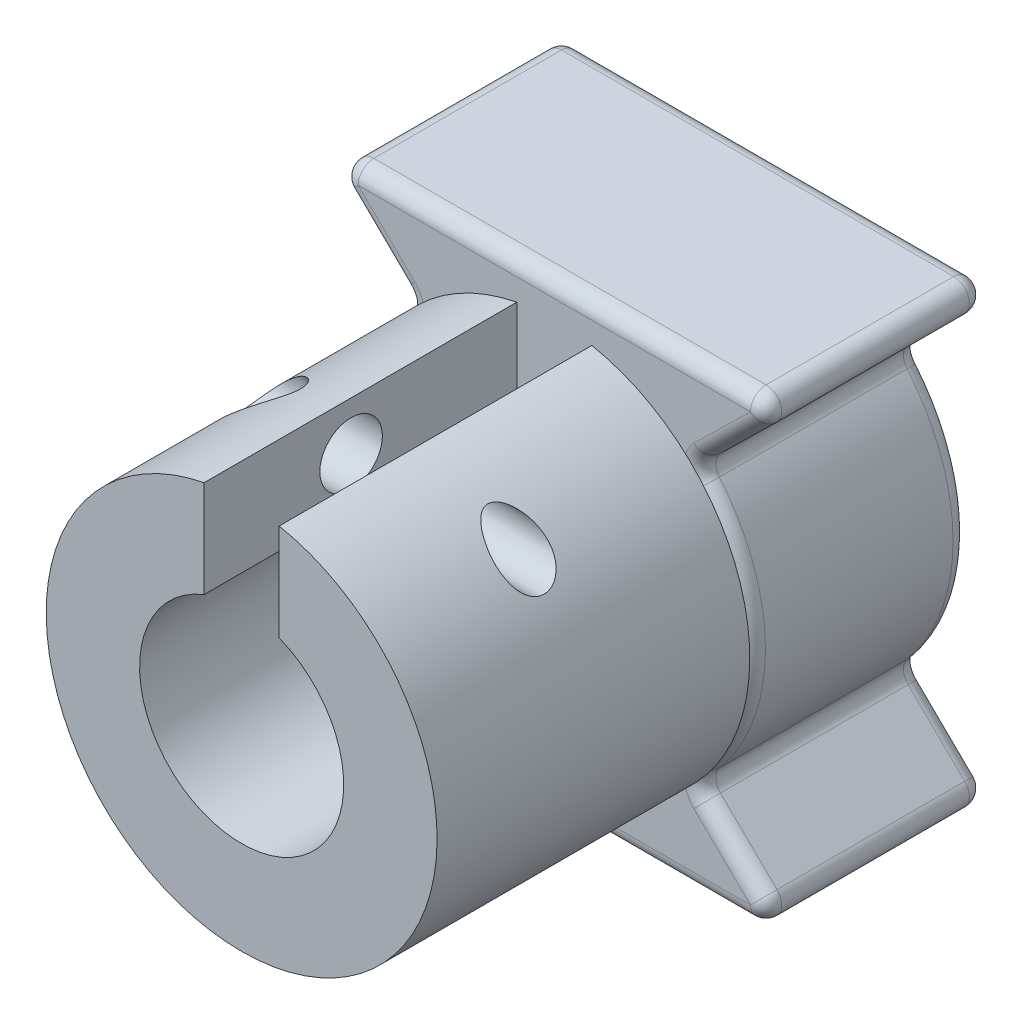
from build123d import *

# Parameters (mm, degrees)
SKETCH1_R           = 6.25
SKETCH1_R_2         = 3.2639
BOSS_EXTRUDE1_DEPTH = 10
SKETCH2_R           = 3.2639
BOSS_EXTRUDE2_DEPTH = 7
SKETCH3_W           = 2.4
SKETCH3_H           = 5.152631641
CUT_EXTRUDE1_DEPTH  = 10
SKETCH4_R           = 1
CUT_EXTRUDE2_DEPTH  = 8.5
SKETCH5_R           = 0.8
M2X_4_THREAD_DEPTH  = 9.5
FILLET2_R           = 0.5


with BuildPart() as part:
    # Sketch1 → Boss-Extrude1 (new body)
    with BuildSketch(Plane.XY):
        Circle(SKETCH1_R)
        Circle(SKETCH1_R_2, mode=Mode.SUBTRACT)
    extrude(amount=BOSS_EXTRUDE1_DEPTH)

    # Sketch3 → Cut-Extrude1 (cut)
    with BuildSketch(Plane.XY.offset(10)):
        with Locations((0, 4.528492236)):
            Rectangle(SKETCH3_W, SKETCH3_H)
    extrude(amount=-CUT_EXTRUDE1_DEPTH, mode=Mode.SUBTRACT)

    # Sketch4 → Cut-Extrude2 (cut, through all)
    with BuildSketch(Plane(origin=(0, 0, 0), x_dir=(0, 0, -1), z_dir=(1, 0, 0))):
        with Locations((-5.3, 4.584508905)):
            Circle(SKETCH4_R)
    extrude(amount=-CUT_EXTRUDE2_DEPTH, mode=Mode.SUBTRACT)

    # Sketch5 → m2x.4 thread (cut)
    with BuildSketch(Plane(origin=(0, 0, 0), x_dir=(0, 0, -1), z_dir=(1, 0, 0))):
        with Locations((-5.3, 4.584508905)):
            Circle(SKETCH5_R)
    extrude(amount=M2X_4_THREAD_DEPTH, mode=Mode.SUBTRACT)


with BuildPart() as body_2:
    # Sketch2 → Boss-Extrude2 (new body)
    with BuildSketch(Plane(origin=(0, 0, 0), x_dir=(-1, 0, 0), z_dir=(0, 0, -1))):
        with BuildLine():
            Line((-7.5, 7.331363016), (7.5, 7.331363016))
            Line((7.5, 7.331363016), (4.469378566, 4.368884896))
            ThreePointArc((4.469378566, 4.368884896), (6.25, 0), (4.469378566, -4.368884896))
            Line((4.469378566, -4.368884896), (7.5, -7.331363016))
            Line((7.5, -7.331363016), (-7.5, -7.331363016))
            Line((-7.5, -7.331363016), (-4.469378566, -4.368884896))
            ThreePointArc((-4.469378566, -4.368884896), (-6.25, 0), (-4.469378566, 4.368884896))
            Line((-4.469378566, 4.368884896), (-7.5, 7.331363016))
        make_face()
        Circle(SKETCH2_R, mode=Mode.SUBTRACT)
    extrude(amount=BOSS_EXTRUDE2_DEPTH)

    # Fillet2
    fillet2_edges = [body_2.edges().sort_by_distance(p)[0] for p in [
        (5.984689283, -5.850123956, -7),
        (6.25, 0, 0),
        (5.984689283, 5.850123956, 0),
        (0, -7.331363016, -7),
        (7.5, 7.331363016, -3.5),
        (-7.5, 7.331363016, -3.5),
        (-4.469378566, 4.368884896, -3.5),
        (-4.469378566, -4.368884896, -3.5),
        (-7.5, -7.331363016, -3.5),
        (7.5, -7.331363016, -3.5),
        (4.469378566, -4.368884896, -3.5),
        (4.469378566, 4.368884896, -3.5),
        (-5.984689283, -5.850123956, -7),
        (-6.25, 0, -7),
        (-5.984689283, 5.850123956, -7),
        (0, 7.331363016, -7),
        (5.984689283, 5.850123956, -7),
        (6.25, 0, -7),
        (0, 7.331363016, 0),
        (-5.984689283, 5.850123956, 0),
        (-6.25, 0, 0),
        (-5.984689283, -5.850123956, 0),
        (0, -7.331363016, 0),
        (5.984689283, -5.850123956, 0),
    ]]
    fillet(fillet2_edges, radius=FILLET2_R)


solid = Compound([part.part, body_2.part])
